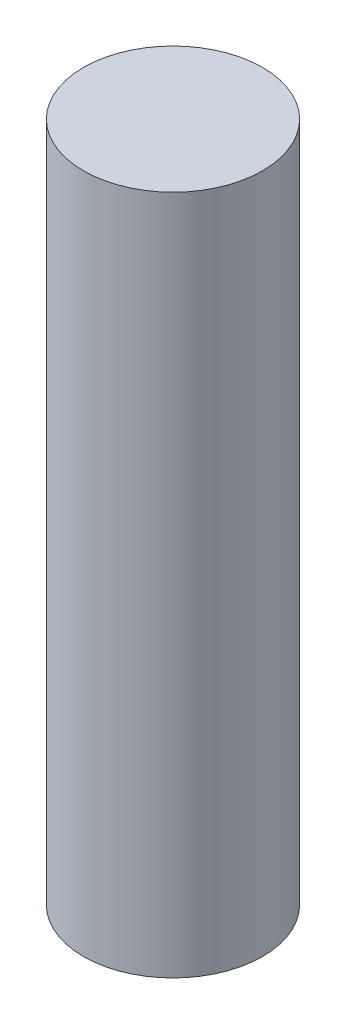
from build123d import *

# Parameters (mm, degrees)
SKETCH1_R           = 1.5
BOSS_EXTRUDE1_DEPTH = 11.4


with BuildPart() as part:
    # Sketch1 → Boss-Extrude1 (new body)
    with BuildSketch(Plane(origin=(0, 0, 0), x_dir=(1, 0, 0), z_dir=(0, 1, 0))):
        Circle(SKETCH1_R)
    extrude(amount=BOSS_EXTRUDE1_DEPTH)


solid = part.part
